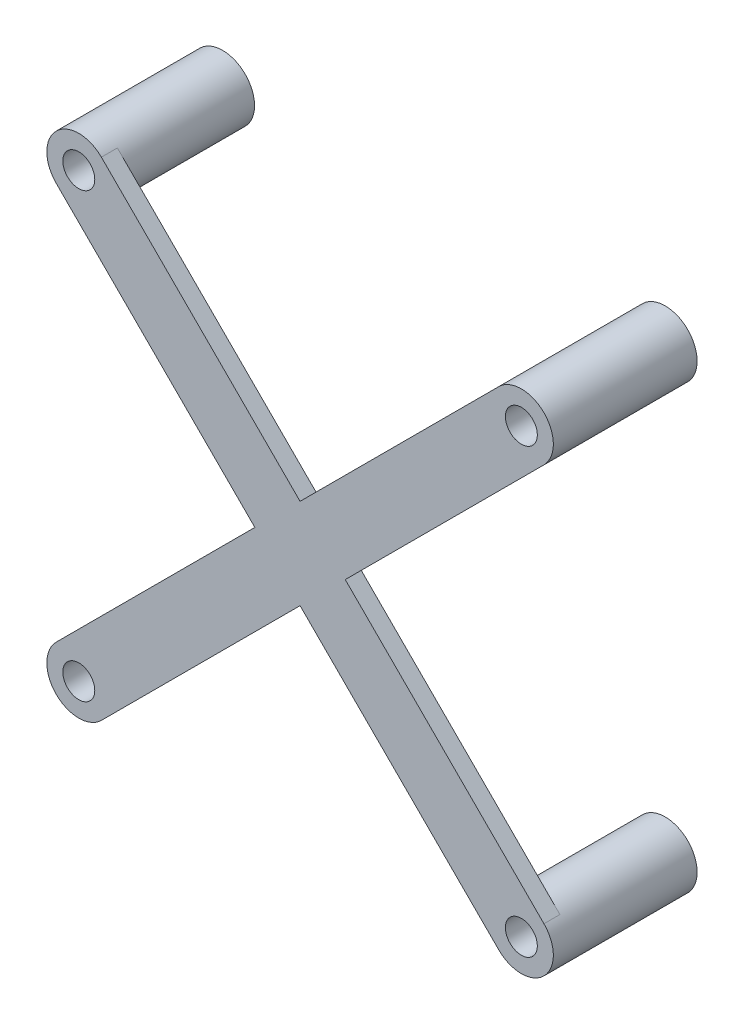
from build123d import *

# Parameters (mm, degrees)
SKETCH3_R               = 2
BOSS_EXTRUDE1_DEPTH     = 8
BOSS_EXTRUDE1_2_DEPTH   = 8
BOSS_EXTRUDE1_3_DEPTH   = 8
BOSS_EXTRUDE1_4_DEPTH   = 8
BOSS_EXTRUDE2_DEPTH     = 1
SKETCH5_R               = 1
CUT_EXTRUDE1_DEPTH      = 10
CUT_EXTRUDE1_DEPTH_BACK = 1


with BuildPart() as part:
    # Sketch3 → Boss-Extrude1 (new body)
    with BuildSketch(Plane(origin=(0, 0, 0), x_dir=(0, 1, 0), z_dir=(0, 0, 1))):
        with Locations((-13.85, 13.85)):
            Circle(SKETCH3_R)
    extrude(amount=BOSS_EXTRUDE1_DEPTH)



with BuildPart() as body_2:
    # Sketch3 → Boss-Extrude1 2 (new body)
    with BuildSketch(Plane(origin=(0, 0, 0), x_dir=(0, 1, 0), z_dir=(0, 0, 1))):
        with Locations((13.85, 13.85)):
            Circle(SKETCH3_R)
    extrude(amount=BOSS_EXTRUDE1_2_DEPTH)


with BuildPart() as body_3:
    # Sketch3 → Boss-Extrude1 3 (new body)
    with BuildSketch(Plane(origin=(0, 0, 0), x_dir=(0, 1, 0), z_dir=(0, 0, 1))):
        with Locations((13.85, -13.85)):
            Circle(SKETCH3_R)
    extrude(amount=BOSS_EXTRUDE1_3_DEPTH)


with BuildPart() as body_4:
    # Sketch3 → Boss-Extrude1 4 (new body)
    with BuildSketch(Plane(origin=(0, 0, 0), x_dir=(0, 1, 0), z_dir=(0, 0, 1))):
        with Locations((-13.85, -13.85)):
            Circle(SKETCH3_R)
    extrude(amount=BOSS_EXTRUDE1_4_DEPTH)


with BuildPart() as part_1:
    add(part.part)

    add(body_2.part)  # Boss-Extrude2 merges body 2

    add(body_3.part)  # Boss-Extrude2 merges body 3

    add(body_4.part)  # Boss-Extrude2 merges body 4
    # Sketch4 → Boss-Extrude2 (add)
    with BuildSketch(Plane.XY.offset(8)):
        with BuildLine():
            Line((-15.264214, -12.435786), (-2.828427, 0))
            Line((-2.828427, 0), (-15.264214, 12.435786))
            ThreePointArc((-15.264214, 12.435786), (-15.264214, 15.264214), (-12.435786, 15.264214))
            Line((-12.435786, 15.264214), (0, 2.828427))
            Line((0, 2.828427), (12.435786, 15.264214))
            ThreePointArc((12.435786, 15.264214), (15.264214, 15.264214), (15.264214, 12.435786))
            Line((15.264214, 12.435786), (2.828427, 0))
            Line((2.828427, 0), (15.264214, -12.435786))
            ThreePointArc((15.264214, -12.435786), (15.264214, -15.264214), (12.435786, -15.264214))
            Line((12.435786, -15.264214), (0, -2.828427))
            Line((0, -2.828427), (-12.435786, -15.264214))
            ThreePointArc((-12.435786, -15.264214), (-15.264214, -15.264214), (-15.264214, -12.435786))
        make_face()
    extrude(amount=BOSS_EXTRUDE2_DEPTH)

    # Sketch5 → Cut-Extrude1 (cut, two sides)
    with BuildSketch(Plane(origin=(0, 0, 0), x_dir=(0, 1, 0), z_dir=(0, 0, 1))) as cut_extrude1_sk:
        with Locations((-13.85, 13.85)):
            Circle(SKETCH5_R)
        with Locations((13.85, 13.85)):
            Circle(SKETCH5_R)
        with Locations((13.85, -13.85)):
            Circle(SKETCH5_R)
        with Locations((-13.85, -13.85)):
            Circle(SKETCH5_R)
    extrude(amount=CUT_EXTRUDE1_DEPTH, mode=Mode.SUBTRACT)
    extrude(cut_extrude1_sk.sketch, amount=-CUT_EXTRUDE1_DEPTH_BACK, mode=Mode.SUBTRACT)


solid = part_1.part
